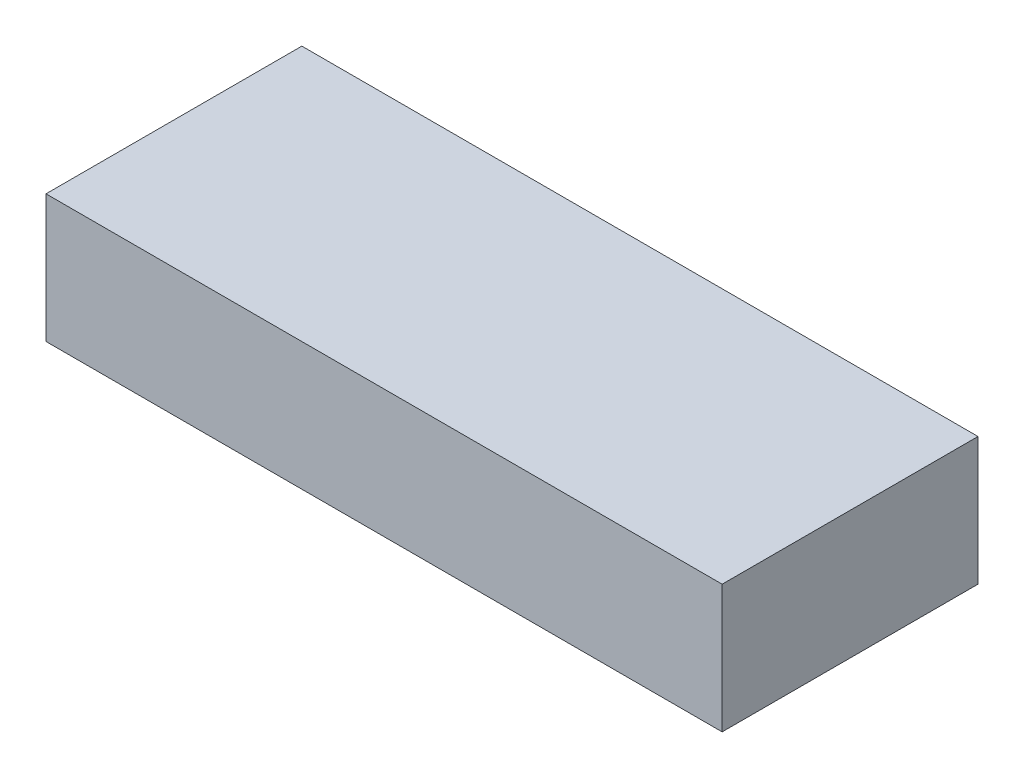
from build123d import *

# Parameters (mm, degrees)
SKETCH1_W           = 370
SKETCH1_H           = 140
BOSS_EXTRUDE1_DEPTH = 35


with BuildPart() as part:
    # Sketch1 → Boss-Extrude1 (new body, symmetric)
    with BuildSketch(Plane(origin=(0, 0, 0), x_dir=(1, 0, 0), z_dir=(0, 1, 0))):
        Rectangle(SKETCH1_W, SKETCH1_H)
    extrude(amount=BOSS_EXTRUDE1_DEPTH, both=True)


solid = part.part
